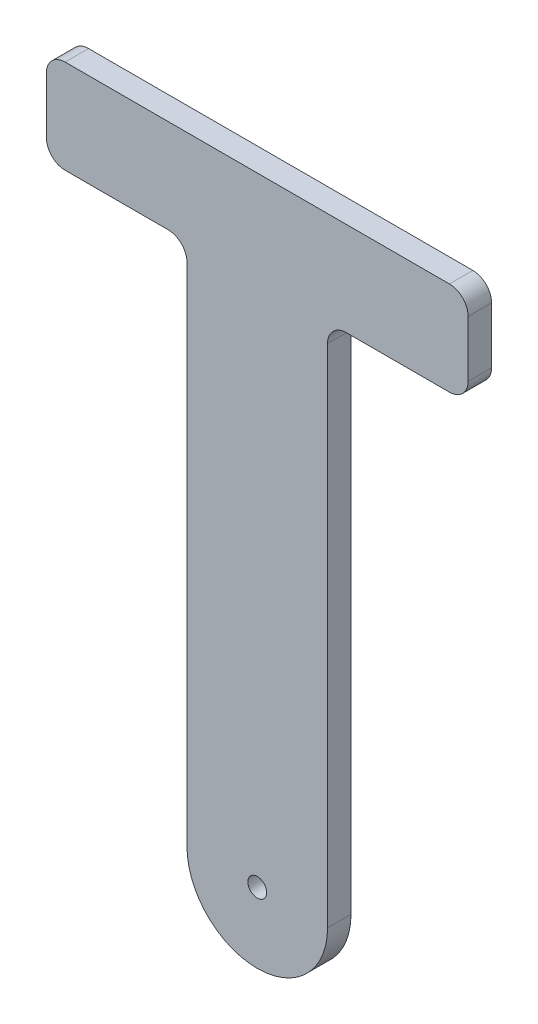
from build123d import *

# Parameters (mm, degrees)
SKETCH1_R           = 1.27
BOSS_EXTRUDE1_DEPTH = 3.175


with BuildPart() as part:
    # Sketch1 → Boss-Extrude1 (new body)
    with BuildSketch(Plane.XY):
        with BuildLine():
            Line((-19.353012887, 0), (-19.353012887, 68.58))
            ThreePointArc((-19.353012887, 68.58), (-20.096961663, 70.376051224), (-21.893012887, 71.12))
            Line((-21.893012887, 71.12), (-35.863012887, 71.12))
            ThreePointArc((-35.863012887, 71.12), (-37.659064112, 71.863948776), (-38.403012887, 73.66))
            Line((-38.403012887, 73.66), (-38.403012887, 81.28))
            ThreePointArc((-38.403012887, 81.28), (-37.659064112, 83.076051224), (-35.863012887, 83.82))
            Line((-35.863012887, 83.82), (16.206987113, 83.82))
            ThreePointArc((16.206987113, 83.82), (18.003038337, 83.076051224), (18.746987113, 81.28))
            Line((18.746987113, 81.28), (18.746987113, 73.66))
            ThreePointArc((18.746987113, 73.66), (18.003038337, 71.863948776), (16.206987113, 71.12))
            Line((16.206987113, 71.12), (2.236987113, 71.12))
            ThreePointArc((2.236987113, 71.12), (0.440935888, 70.376051224), (-0.303012887, 68.58))
            Line((-0.303012887, 68.58), (-0.303012887, 0))
            ThreePointArc((-0.303012887, 0), (-9.828012887, -9.525), (-19.353012887, 0))
        make_face()
        with Locations((-9.828012887, 0)):
            Circle(SKETCH1_R, mode=Mode.SUBTRACT)
    extrude(amount=BOSS_EXTRUDE1_DEPTH)


solid = part.part
